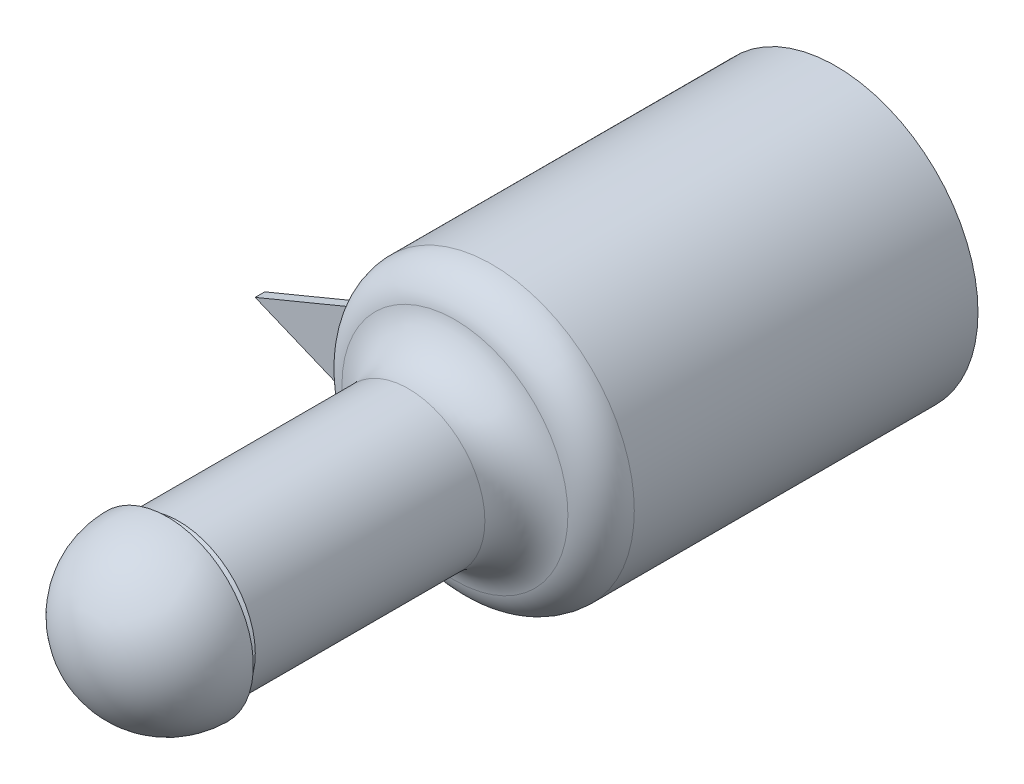
from build123d import *

# Parameters (mm, degrees)
SKETCH2_R           = 7.45
BOSS_EXTRUDE1_DEPTH = 10
SKETCH3_R           = 4
BOSS_EXTRUDE2_DEPTH = 15
FILLET7_R           = 2
FILLET12_R          = 2.5
REVOLVE1_ANGLE      = 180
CUT_EXTRUDE4_START  = -3.5
CUT_EXTRUDE4_DEPTH  = 1
CUT_EXTRUDE5_START  = -5
SKETCH20_R          = 1
CUT_EXTRUDE5_DEPTH  = 5
BOSS_EXTRUDE3_DEPTH = 0.25
CUT_EXTRUDE6_DEPTH  = 15


with BuildPart() as part:
    # Sketch2 → Boss-Extrude1 (new body, symmetric)
    with BuildSketch(Plane.XY):
        Circle(SKETCH2_R)
    extrude(amount=BOSS_EXTRUDE1_DEPTH, both=True)

    # Sketch3 → Boss-Extrude2 (add)
    with BuildSketch(Plane.XY.offset(10)):
        Circle(SKETCH3_R)
    extrude(amount=BOSS_EXTRUDE2_DEPTH)

    # Fillet7
    fillet7_edges = [part.edges().sort_by_distance(p)[0] for p in [
        (-7.45, 0, 10),
    ]]
    fillet(fillet7_edges, radius=FILLET7_R)

    # Fillet12
    fillet12_edges = [part.edges().sort_by_distance(p)[0] for p in [
        (-4, 0, 10),
    ]]
    fillet(fillet12_edges, radius=FILLET12_R)

    # Sketch4 → Revolve1 (revolve)
    with BuildSketch(Plane.XY.offset(25)):
        with BuildLine():
            Line((0, 4.5), (0, -4.5))
            ThreePointArc((0, -4.5), (-4.5, 0), (0, 4.5))
        make_face()
    revolve(axis=Axis((0, 4.5, 25), (0, 1, 0)), revolution_arc=REVOLVE1_ANGLE)

    # Sketch18 → Cut-Revolve18 (revolve, cut)
    with BuildSketch(Plane(origin=(0, 0, 0), x_dir=(1, 0, 0), z_dir=(0, 1, 0))):
        Polygon((4, -25), (3.2, -25), (4, -24.4), align=None)
    revolve(axis=Axis((0, 0, 22.4216759), (0, 0, -1)), mode=Mode.SUBTRACT)

    # Sketch19 → Cut-Extrude4 (cut)
    with BuildSketch(Plane(origin=(0, 0, 0), x_dir=(1, 0, 0), z_dir=(0, 1, 0)).offset(CUT_EXTRUDE4_START)):
        Polygon((-1.5, -24.1), (-1.5, -20.4), (1.5, -20.4), (1.5, -24.1), (1.17, -24.7), (-1.167506704, -24.7), align=None)
    extrude(amount=-CUT_EXTRUDE4_DEPTH, mode=Mode.SUBTRACT)

    # Sketch20 → Cut-Extrude5 (cut)
    with BuildSketch(Plane(origin=(0, 0, 0), x_dir=(1, 0, 0), z_dir=(0, 1, 0)).offset(CUT_EXTRUDE5_START)):
        with Locations((0, -2)):
            Circle(SKETCH20_R)
    extrude(amount=-CUT_EXTRUDE5_DEPTH, mode=Mode.SUBTRACT)

    # Sketch26 → Cut-Extrude6 (cut)
    with BuildSketch(Plane(origin=(0, 0, -10), x_dir=(-1, 0, 0), z_dir=(0, 0, -1))):
        with BuildLine():
            Line((3.2, 2.4), (3.2, -2.4))
            ThreePointArc((3.2, -2.4), (-4, 0), (3.2, 2.4))
        make_face()
    extrude(amount=-CUT_EXTRUDE6_DEPTH, mode=Mode.SUBTRACT)


with BuildPart() as body_2:
    # Sketch24 → Boss-Extrude3 (new body, symmetric)
    with BuildSketch(Plane.XY.offset(8)):
        with BuildLine():
            Line((-7.156338318, 2.071067812), (-12.156338318, 0))
            Line((-12.156338318, 0), (-7.156338318, -2.071067812))
            ThreePointArc((-7.156338318, -2.071067812), (-7.45, 0), (-7.156338318, 2.071067812))
        make_face()
    extrude(amount=BOSS_EXTRUDE3_DEPTH, both=True)


solid = Compound([part.part, body_2.part])
